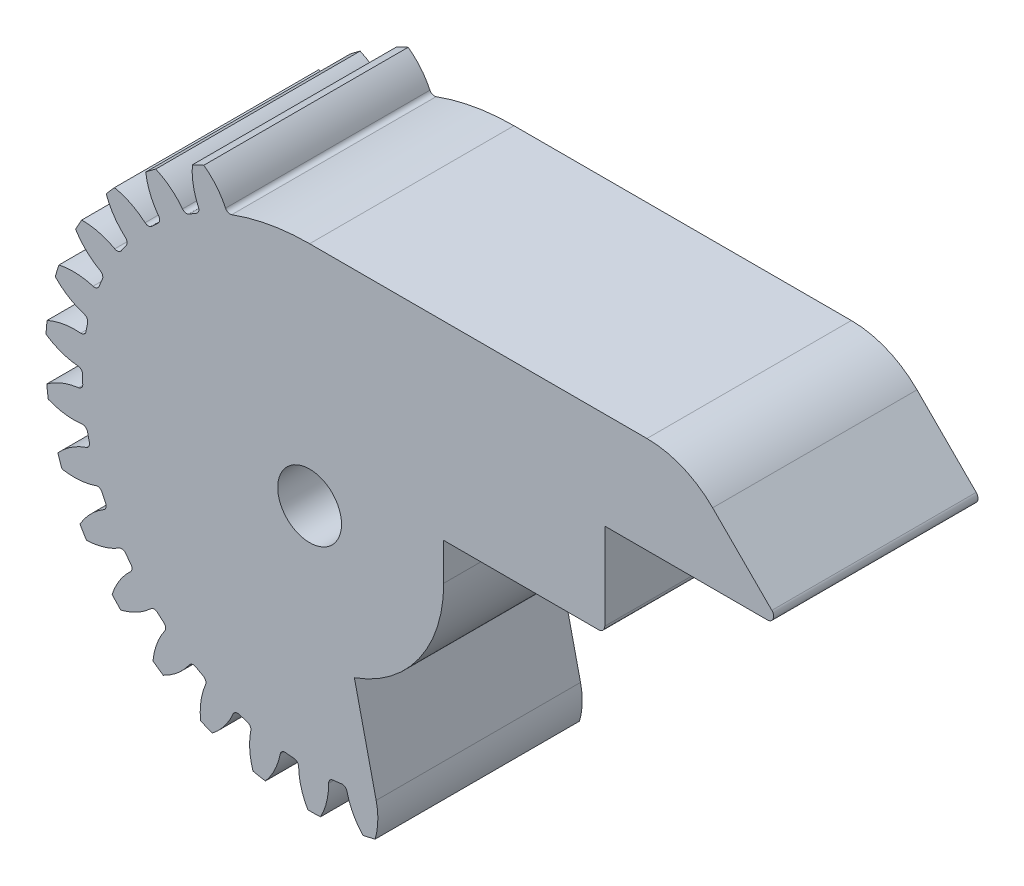
from build123d import *

# Parameters (mm, degrees)
SKBASE_R                                = 21.328
BASE_DEPTH                              = 8.25
TOOTHPROFILE_DEPTH                      = 32.270268115
FILLETTOOTHPROFILE_R                    = 0.3999
CIRPATTERNTEETH_COUNT                   = 30
FILLETTOOTHPROFILE_OF_CIRPATTERNTEETH_R = 0.3999
SKCHAVETA_R                             = 2.575
CHAVETA_DEPTH                           = 35.337268481
BODY_MOVE_COPY1_ANGLE                   = 6.99
CUT_EXTRUDE1_DEPTH                      = 16.5
BOSS_EXTRUDE1_DEPTH                     = 16.5
SKETCH10_R                              = 5
SKETCH10_R_2                            = 2.575
BOSS_EXTRUDE2_DEPTH                     = 1.65
FILLET1_R                               = 0.5
FILLET2_R                               = 7.5
CHAMFER1_SIZE                           = 2
SKETCH11_W                              = 5.5
SKETCH11_H                              = 3
CUT_EXTRUDE2_DEPTH                      = 16.5
FILLET3_R                               = 0.5
CUT_EXTRUDE3_DEPTH                      = 47.774652568


with BuildPart() as part:
    # skBase → Base (new, symmetric)
    with BuildSketch(Plane.XY):
        Circle(SKBASE_R)
    extrude(amount=BASE_DEPTH, both=True)

    # skToothProfile → ToothProfile (cut, symmetric)
    with BuildSketch(Plane.XY):
        with BuildLine():
            ThreePointArc((-0.721312484, 18.314551178), (-1.241450703, 20.43474689), (-2.550404893, 22.181862385))
            ThreePointArc((-2.550404893, 22.181862385), (0, 22.328), (2.550404893, 22.181862385))
            ThreePointArc((2.550404893, 22.181862385), (1.241450703, 20.43474689), (0.721312484, 18.314551178))
            ThreePointArc((0.721312484, 18.314551178), (0, 18.32875), (-0.721312484, 18.314551178))
        make_face()
    toothprofile = extrude(amount=TOOTHPROFILE_DEPTH, both=True, mode=Mode.SUBTRACT)

    # FilletToothProfile
    fillettoothprofile_edges = [part.edges().sort_by_distance(p)[0] for p in [
        (-0.721312484, 18.314551178, 0),
        (0.721312484, 18.314551178, 0),
    ]]
    fillet(fillettoothprofile_edges, radius=FILLETTOOTHPROFILE_R)

    # CirPatternTeeth: ToothProfile ×30 about axis
    cirpatternteeth_axis = Axis((0, 0, 0), (0, 0, 1))
    for i in range(1, CIRPATTERNTEETH_COUNT):
        add(toothprofile.rotate(cirpatternteeth_axis, i * 360 / CIRPATTERNTEETH_COUNT), mode=Mode.SUBTRACT)

    # FilletToothProfile of CirPatternTeeth
    fillettoothprofile_of_cirpatternteeth_edges = [part.edges().sort_by_distance(p)[0] for p in [
        (-4.513359377, 17.764364995, 0),
        (-3.102259227, 18.064303592, 0),
        (-8.108150809, 16.437790819, 0),
        (-6.790247323, 17.024559256, 0),
        (-11.348577143, 14.392806307, 0),
        (-10.181469027, 15.240759988, 0),
        (-14.093016199, 11.718787095, 0),
        (-13.127711679, 12.790866375, 0),
        (-16.221522821, 8.532600654, 0),
        (-15.500210337, 9.781950524, 0),
        (-17.641071057, 4.97349862, 0),
        (-17.195275425, 6.345516496, 0),
        (-18.289619836, 1.197030832, 0),
        (-18.138824465, 2.631752949, 0),
        (-18.138824465, -2.631752949, 0),
        (-18.289619836, -1.197030832, 0),
        (-17.195275425, -6.345516496, 0),
        (-17.641071057, -4.97349862, 0),
        (-15.500210337, -9.781950524, 0),
        (-16.221522821, -8.532600654, 0),
        (-13.127711679, -12.790866375, 0),
        (-14.093016199, -11.718787095, 0),
        (-10.181469027, -15.240759988, 0),
        (-11.348577143, -14.392806307, 0),
        (-6.790247323, -17.024559256, 0),
        (-8.108150809, -16.437790819, 0),
        (-3.102259227, -18.064303592, 0),
        (-4.513359377, -17.764364995, 0),
        (0.721312484, -18.314551178, 0),
        (-0.721312484, -18.314551178, 0),
        (4.513359377, -17.764364995, 0),
        (3.102259227, -18.064303592, 0),
        (8.108150809, -16.437790819, 0),
        (6.790247323, -17.024559256, 0),
        (11.348577143, -14.392806307, 0),
        (10.181469027, -15.240759988, 0),
        (14.093016199, -11.718787095, 0),
        (13.127711679, -12.790866375, 0),
        (16.221522821, -8.532600654, 0),
        (15.500210337, -9.781950524, 0),
        (17.641071057, -4.97349862, 0),
        (17.195275425, -6.345516496, 0),
        (18.289619836, -1.197030832, 0),
        (18.138824465, -2.631752949, 0),
        (18.138824465, 2.631752949, 0),
        (18.289619836, 1.197030832, 0),
        (17.195275425, 6.345516496, 0),
        (17.641071057, 4.97349862, 0),
        (15.500210337, 9.781950524, 0),
        (16.221522821, 8.532600654, 0),
        (13.127711679, 12.790866375, 0),
        (14.093016199, 11.718787095, 0),
        (10.181469027, 15.240759988, 0),
        (11.348577143, 14.392806307, 0),
        (6.790247323, 17.024559256, 0),
        (8.108150809, 16.437790819, 0),
        (3.102259227, 18.064303592, 0),
        (4.513359377, 17.764364995, 0),
    ]]
    fillet(fillettoothprofile_of_cirpatternteeth_edges, radius=FILLETTOOTHPROFILE_OF_CIRPATTERNTEETH_R)

    # skChaveta → Chaveta (cut, through all)
    with BuildSketch(Plane.XY.offset(8.25)):
        Circle(SKCHAVETA_R)
    extrude(amount=-CHAVETA_DEPTH, mode=Mode.SUBTRACT)


with BuildPart() as part_1:
    # Body-Move/Copy1: moved
    add(part.part.rotate(Axis((0, 0, 0), (0, 0, 1)), BODY_MOVE_COPY1_ANGLE))

    # Sketch7 → Cut-Extrude1 (cut)
    with BuildSketch(Plane(origin=(0, 0, -8.25), x_dir=(-1, 0, 0), z_dir=(0, 0, -1))):
        with BuildLine():
            ThreePointArc((2.57078661, 18.147565478), (4.119954594, 17.859704665), (5.638674078, 17.439851811))
            ThreePointArc((5.638674078, 17.439851811), (5.414025275, 17.622765897), (5.37183302, 17.909374448))
            ThreePointArc((5.37183302, 17.909374448), (5.506341406, 19.291055726), (5.288162079, 20.6620165))
            ThreePointArc((5.288162079, 20.6620165), (4.794128982, 20.782201792), (4.297371351, 20.890576428))
            ThreePointArc((4.297371351, 20.890576428), (3.500680209, 19.753730402), (3.016340437, 18.452749754))
            ThreePointArc((3.016340437, 18.452749754), (2.852860845, 18.213586482), (2.57078661, 18.147565478))
        make_face()
        with BuildLine():
            ThreePointArc((-1.258482268, 18.285494222), (0.316682306, 18.326013993), (1.889506443, 18.231095468))
            ThreePointArc((1.889506443, 18.231095468), (1.631736778, 18.36330533), (1.530877258, 18.634878533))
            ThreePointArc((1.530877258, 18.634878533), (1.375178622, 20.014332626), (0.876728264, 21.309972584))
            ThreePointArc((0.876728264, 21.309972584), (0.368503048, 21.324816283), (-0.139931591, 21.327540954))
            ThreePointArc((-0.139931591, 21.327540954), (-0.68284954, 20.049896339), (-0.88611624, 18.676645339))
            ThreePointArc((-0.88611624, 18.676645339), (-0.99629857, 18.40871904), (-1.258482268, 18.285494222))
        make_face()
        with BuildLine():
            ThreePointArc((-5.032749433, 17.624259125), (-3.500430517, 17.991388572), (-1.942241691, 18.22555277))
            ThreePointArc((-1.942241691, 18.22555277), (-2.221866445, 18.301280202), (-2.376985187, 18.545949006))
            ThreePointArc((-2.376985187, 18.545949006), (-2.816086067, 19.862887151), (-3.573022784, 21.026580611))
            ThreePointArc((-3.573022784, 21.026580611), (-4.073228238, 20.935433975), (-4.571118851, 20.8323896))
            ThreePointArc((-4.571118851, 20.8323896), (-4.836535488, 19.469785597), (-4.749845385, 18.084281902))
            ThreePointArc((-4.749845385, 18.084281902), (-4.801914958, 17.799302242), (-5.032749433, 17.624259125))
        make_face()
        with BuildLine():
            ThreePointArc((-8.587061297, 16.192759334), (-7.16455773, 16.870453138), (-5.689104542, 17.42346596))
            ThreePointArc((-5.689104542, 17.42346596), (-5.978363444, 17.439401311), (-6.180961974, 17.646472514))
            ThreePointArc((-6.180961974, 17.646472514), (-6.884274282, 18.843338195), (-7.86661559, 19.824226168))
            ThreePointArc((-7.86661559, 19.824226168), (-8.336939904, 19.631072743), (-8.802526282, 19.426762856))
            ThreePointArc((-8.802526282, 19.426762856), (-8.778841627, 18.038751797), (-8.405983495, 16.701548569))
            ThreePointArc((-8.405983495, 16.701548569), (-8.397664619, 16.411970524), (-8.587061297, 16.192759334))
        make_face()
        with BuildLine():
            ThreePointArc((-6.786968563, -17.422380458), (-6.577336552, -17.222432796), (-6.287699777, -17.21650104))
            ThreePointArc((-6.287699777, -17.21650104), (-7.743165095, -16.612840542), (-9.141404598, -15.886402945))
            ThreePointArc((-9.141404598, -15.886402945), (-8.959694888, -16.112027032), (-8.978013903, -16.40114476))
            ThreePointArc((-8.978013903, -16.40114476), (-9.396850649, -17.724667122), (-9.468477836, -19.111031146))
            ThreePointArc((-9.468477836, -19.111031146), (-9.010228474, -19.331305358), (-8.546858543, -19.540593467))
            ThreePointArc((-8.546858543, -19.540593467), (-7.531213435, -18.594231657), (-6.786968563, -17.422380458))
        make_face()
        with BuildLine():
            ThreePointArc((-11.766077377, 14.053558258), (-10.515559391, 15.012197949), (-9.187326226, 15.859890081))
            ThreePointArc((-9.187326226, 15.859890081), (-9.473577272, 15.815336899), (-9.714801062, 15.975760496))
            ThreePointArc((-9.714801062, 15.975760496), (-10.651586677, 17.000244939), (-11.816399547, 17.755457914))
            ThreePointArc((-11.816399547, 17.755457914), (-12.236287291, 17.468739432), (-12.649221076, 17.172093354))
            ThreePointArc((-12.649221076, 17.172093354), (-12.337470261, 15.819337985), (-11.694739789, 14.58887742))
            ThreePointArc((-11.694739789, 14.58887742), (-11.62639604, 14.307356942), (-11.766077377, 14.053558258))
        make_face()
        with BuildLine():
            ThreePointArc((-10.260973596, -15.630569535), (-10.014351091, -15.478576155), (-9.729810292, -15.532992894))
            ThreePointArc((-9.729810292, -15.532992894), (-11.027962126, -14.63991557), (-12.244611872, -13.638642039))
            ThreePointArc((-12.244611872, -13.638642039), (-12.11378284, -13.897115271), (-12.191812497, -14.176106346))
            ThreePointArc((-12.191812497, -14.176106346), (-12.876672427, -15.383625512), (-13.234975677, -16.724802027))
            ThreePointArc((-13.234975677, -16.724802027), (-12.832537747, -17.035538118), (-12.422807005, -17.336592806))
            ThreePointArc((-12.422807005, -17.336592806), (-11.232596496, -16.622075763), (-10.260973596, -15.630569535))
        make_face()
        with BuildLine():
            ThreePointArc((-14.430859416, 11.300149251), (-13.406980647, 12.497837673), (-12.284017668, 13.603160901))
            ThreePointArc((-12.284017668, 13.603160901), (-12.554750315, 13.500066374), (-12.824056727, 13.606831084))
            ThreePointArc((-12.824056727, 13.606831084), (-13.953373621, 14.414159403), (-15.249750143, 14.910690949))
            ThreePointArc((-15.249750143, 14.910690949), (-15.600850207, 14.542938383), (-15.943084211, 14.166920973))
            ThreePointArc((-15.943084211, 14.166920973), (-15.356892243, 12.908543193), (-14.472379838, 11.838602322))
            ThreePointArc((-14.472379838, 11.838602322), (-14.346998165, 11.577443207), (-14.430859416, 11.300149251))
        make_face()
        with BuildLine():
            ThreePointArc((-13.286524844, -13.155627719), (-13.013690432, -13.058231461), (-12.746681409, -13.170618422))
            ThreePointArc((-12.746681409, -13.170618422), (-13.830784294, -12.027156038), (-14.812670852, -10.794807029))
            ThreePointArc((-14.812670852, -10.794807029), (-14.738440354, -11.074832887), (-14.872770383, -11.33150406))
            ThreePointArc((-14.872770383, -11.33150406), (-15.793721831, -12.370245649), (-16.423041572, -13.607618804))
            ThreePointArc((-16.423041572, -13.607618804), (-16.094003543, -13.995236117), (-15.75581919, -14.374899849))
            ThreePointArc((-15.75581919, -14.374899849), (-14.443061189, -13.923455397), (-13.286524844, -13.155627719))
        make_face()
        with BuildLine():
            ThreePointArc((-16.464943651, 8.052869496), (-15.712452515, 9.437261919), (-14.843838593, 10.751908314))
            ThreePointArc((-14.843838593, 10.751908314), (-15.087220524, 10.594778167), (-15.372839577, 10.643217862))
            ThreePointArc((-15.372839577, 10.643217862), (-16.645331183, 11.198105934), (-18.01661348, 11.414255241))
            ThreePointArc((-18.01661348, 11.414255241), (-18.283581108, 10.981541142), (-18.540158062, 10.542586164))
            ThreePointArc((-18.540158062, 10.542586164), (-17.705144343, 9.433583121), (-16.617507441, 8.570923495))
            ThreePointArc((-16.617507441, 8.570923495), (-16.440567625, 8.341539649), (-16.464943651, 8.052869496))
        make_face()
        with BuildLine():
            ThreePointArc((-15.731391201, -10.105721844), (-15.444269055, -10.067179392), (-15.206461383, -10.232624726))
            ThreePointArc((-15.206461383, -10.232624726), (-16.029134821, -8.888752074), (-16.733345036, -7.479187154))
            ThreePointArc((-16.733345036, -7.479187154), (-16.718957302, -7.768527163), (-16.903716835, -7.991660671))
            ThreePointArc((-16.903716835, -7.991660671), (-18.020509805, -8.816226692), (-18.893341744, -9.895717344))
            ThreePointArc((-18.893341744, -9.895717344), (-18.652084156, -10.343275141), (-18.400226471, -10.78495479))
            ThreePointArc((-18.400226471, -10.78495479), (-17.022294803, -10.616313218), (-15.731391201, -10.105721844))
        make_face()
        with BuildLine():
            ThreePointArc((-17.779430842, 4.453640703), (-17.331214811, 5.964232534), (-16.754912542, 7.430745741))
            ThreePointArc((-16.754912542, 7.430745741), (-16.9603068, 7.226447316), (-17.24975557, 7.214444946))
            ThreePointArc((-17.24975557, 7.214444946), (-18.609807899, 7.492641502), (-19.996064356, 7.418961806))
            ThreePointArc((-19.996064356, 7.418961806), (-20.167231781, 6.940197858), (-20.326938041, 6.457489751))
            ThreePointArc((-20.326938041, 6.457489751), (-19.279596677, 5.5463302), (-18.036370229, 4.928654184))
            ThreePointArc((-18.036370229, 4.928654184), (-17.81560539, 4.741070781), (-17.779430842, 4.453640703))
        make_face()
        with BuildLine():
            ThreePointArc((-17.488720275, -6.614147432), (-17.19985901, -6.636143276), (-17.001646025, -6.847416227))
            ThreePointArc((-17.001646025, -6.847416227), (-17.52693524, -5.361866992), (-17.922691746, -3.836690911))
            ThreePointArc((-17.922691746, -3.836690911), (-17.96877559, -4.122699524), (-18.195889748, -4.302543363))
            ThreePointArc((-18.195889748, -4.302543363), (-19.459715028, -4.876896323), (-20.537912221, -5.75132555))
            ThreePointArc((-20.537912221, -5.75132555), (-20.394979189, -6.239263409), (-20.240455561, -6.723655455))
            ThreePointArc((-20.240455561, -6.723655455), (-18.857572452, -6.845187209), (-17.488720275, -6.614147432))
        make_face()
        with BuildLine():
            ThreePointArc((-18.316871589, 0.65976644), (-18.192519856, 2.230537568), (-17.933716415, 3.784823922))
            ThreePointArc((-17.933716415, 3.784823922), (-18.092146284, 3.54228604), (-18.372774471, 3.470366168))
            ThreePointArc((-18.372774471, 3.470366168), (-19.76094671, 3.459712682), (-21.101591267, 3.099424141))
            ThreePointArc((-21.101591267, 3.099424141), (-21.169477651, 2.595534625), (-21.225333287, 2.09017005))
            ThreePointArc((-21.225333287, 2.09017005), (-20.011438122, 1.416676034), (-18.66695709, 1.070979034))
            ThreePointArc((-18.66695709, 1.070979034), (-18.41201571, 0.933394369), (-18.316871589, 0.65976644))
        make_face()
        with BuildLine():
            ThreePointArc((-18.481708353, -2.833503038), (-18.203732593, -2.915075855), (-18.053777154, -3.162942782))
            ThreePointArc((-18.053777154, -3.162942782), (-18.258724486, -1.600642593), (-18.328730824, -0.026512864))
            ThreePointArc((-18.328730824, -0.026512864), (-18.43327216, -0.296690133), (-18.692814965, -0.425384264))
            ThreePointArc((-18.692814965, -0.425384264), (-20.048437326, -0.724422183), (-21.284877383, -1.355573232))
            ThreePointArc((-21.284877383, -1.355573232), (-21.246515765, -1.862565926), (-21.196079619, -2.368500112))
            ThreePointArc((-21.196079619, -2.368500112), (-19.868683696, -2.774893672), (-18.481708353, -2.833503038))
        make_face()
    extrude(amount=-CUT_EXTRUDE1_DEPTH, mode=Mode.SUBTRACT)

    # Sketch9 → Boss-Extrude1 (add)
    with BuildSketch(Plane(origin=(0, 0, -8.25), x_dir=(-1, 0, 0), z_dir=(0, 0, -1))):
        with BuildLine():
            Line((-23.82875, 0), (-18.32875, 0))
            ThreePointArc((-18.32875, 0), (-12.960383416, 12.960383416), (0, 18.32875))
            Line((0, 18.32875), (-30.3425, 18.32875))
            Line((-30.3425, 18.32875), (-38.17125, 10.5))
            Line((-38.17125, 10.5), (-23.82875, 10.5))
            Line((-23.82875, 10.5), (-23.82875, 0))
        make_face()
    extrude(amount=-BOSS_EXTRUDE1_DEPTH)

    # Sketch10 → Boss-Extrude2 (add)
    with BuildSketch(Plane(origin=(0, 0, -8.25), x_dir=(-1, 0, 0), z_dir=(0, 0, -1))):
        with Locations(Location((0, 0, 0), (0, 0, 180))):
            Circle(SKETCH10_R)
        with Locations(Location((0, 0, 0), (0, 0, 173.01))):
            Circle(SKETCH10_R_2, mode=Mode.SUBTRACT)
    extrude(amount=BOSS_EXTRUDE2_DEPTH)

    # Fillet1
    fillet1_edges = [part_1.edges().sort_by_distance(p)[0] for p in [
        (38.17125, 10.5, 0),
    ]]
    fillet(fillet1_edges, radius=FILLET1_R)

    # Fillet2
    fillet2_edges = [part_1.edges().sort_by_distance(p)[0] for p in [
        (30.3425, 18.32875, 0),
    ]]
    fillet(fillet2_edges, radius=FILLET2_R)

    # Chamfer1
    chamfer1_edges = [part_1.edges().sort_by_distance(p)[0] for p in [
        (23.82875, 0, 0),
    ]]
    chamfer(chamfer1_edges, length=CHAMFER1_SIZE)

    # Sketch11 → Cut-Extrude2 (cut)
    with BuildSketch(Plane.XY.offset(8.25)):
        with Locations((21.07875, 1.5)):
            Rectangle(SKETCH11_W, SKETCH11_H)
    extrude(amount=-CUT_EXTRUDE2_DEPTH, mode=Mode.SUBTRACT)

    # Fillet3
    fillet3_edges = [part_1.edges().sort_by_distance(p)[0] for p in [
        (23.82875, 3, 0),
    ]]
    fillet(fillet3_edges, radius=FILLET3_R)

    # Sketch12 → Cut-Extrude3 (cut, through all)
    with BuildSketch(Plane.XY.offset(8.25)):
        with BuildLine():
            Line((10.82875, 0), (10.82875, 3))
            Line((10.82875, 3), (18.32875, 3))
            Line((18.32875, 3), (18.32875, 0))
            ThreePointArc((18.32875, 0), (14.82047442, -10.784090807), (5.638674078, -17.439851811))
            ThreePointArc((5.638674078, -17.439851811), (5.414025275, -17.622765897), (5.37183302, -17.909374448))
            Line((5.37183302, -17.909374448), (3.613426549, -10.208083813))
            ThreePointArc((3.613426549, -10.208083813), (8.842814012, -6.250317345), (10.82875, 0))
        make_face()
    extrude(amount=-CUT_EXTRUDE3_DEPTH, mode=Mode.SUBTRACT)


solid = part_1.part
